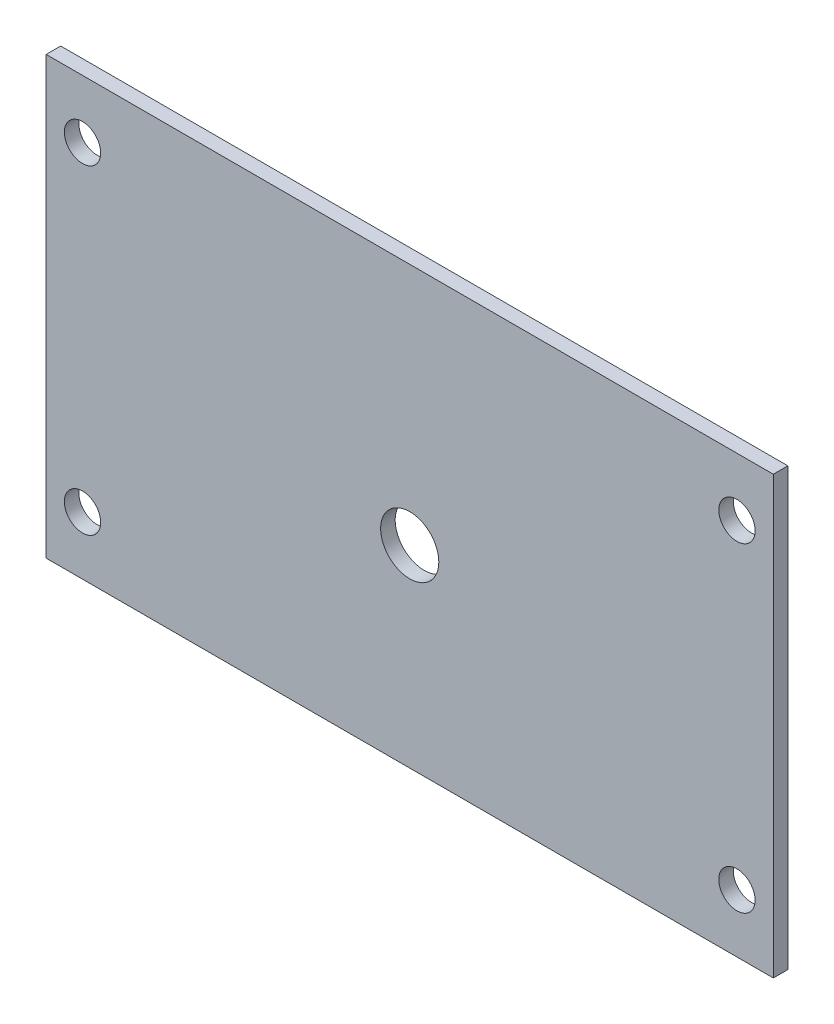
from build123d import *

# Parameters (mm, degrees)
SKETCH1_W           = 100
SKETCH1_H           = 60
SKETCH1_R           = 4
SKETCH1_R_2         = 2.5
BOSS_EXTRUDE1_DEPTH = 2


with BuildPart() as part:
    # Sketch1 → Boss-Extrude1 (new body)
    with BuildSketch(Plane.XY):
        Rectangle(SKETCH1_W, SKETCH1_H)
        with Locations((0, -3.458840457)):
            Circle(SKETCH1_R, mode=Mode.SUBTRACT)
        with Locations((-45, 22)):
            Circle(SKETCH1_R_2, mode=Mode.SUBTRACT)
        with Locations((-45, -22)):
            Circle(SKETCH1_R_2, mode=Mode.SUBTRACT)
        with Locations((45, -22)):
            Circle(SKETCH1_R_2, mode=Mode.SUBTRACT)
        with Locations((45, 22)):
            Circle(SKETCH1_R_2, mode=Mode.SUBTRACT)
    extrude(amount=BOSS_EXTRUDE1_DEPTH)


solid = part.part
